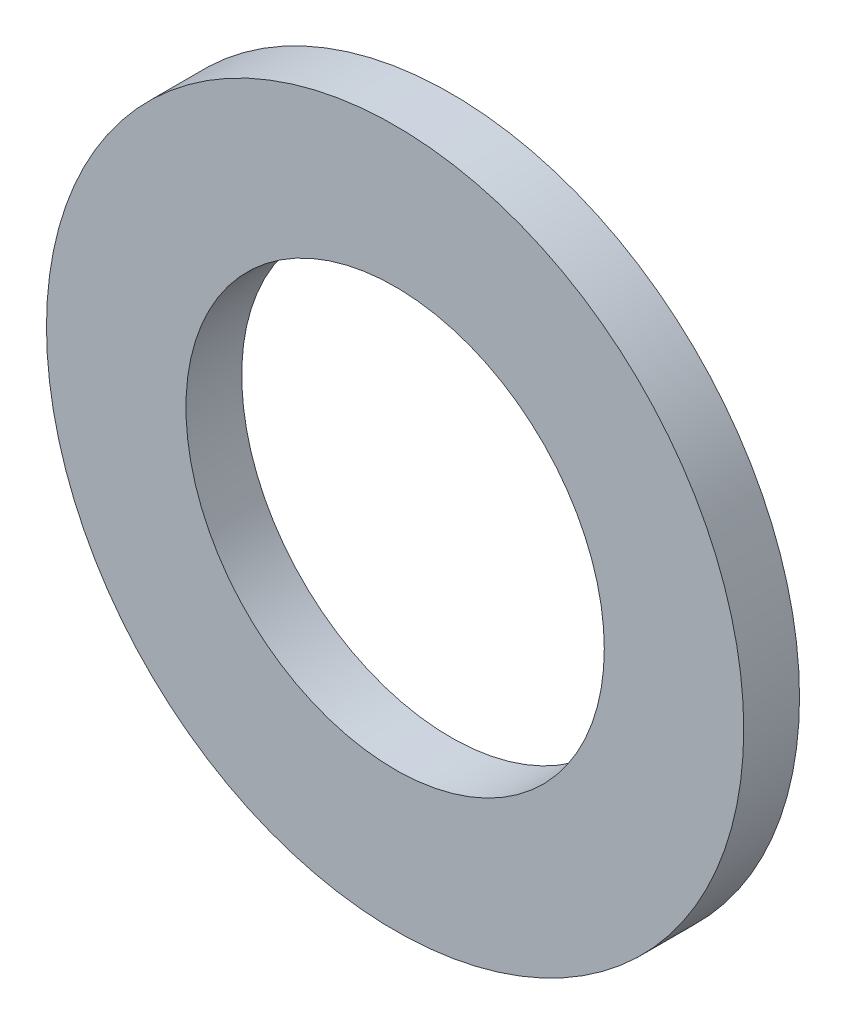
from build123d import *

# Parameters (mm, degrees)
SKETCH_1_R      = 2.5
SKETCH_1_R_2    = 1.5
EXTRUDE_1_DEPTH = 0.4


with BuildPart() as part:
    # 草图1 → 凸台-拉伸1 (new body)
    with BuildSketch(Plane.XY):
        Circle(SKETCH_1_R)
        Circle(SKETCH_1_R_2, mode=Mode.SUBTRACT)
    extrude(amount=EXTRUDE_1_DEPTH)


solid = part.part
